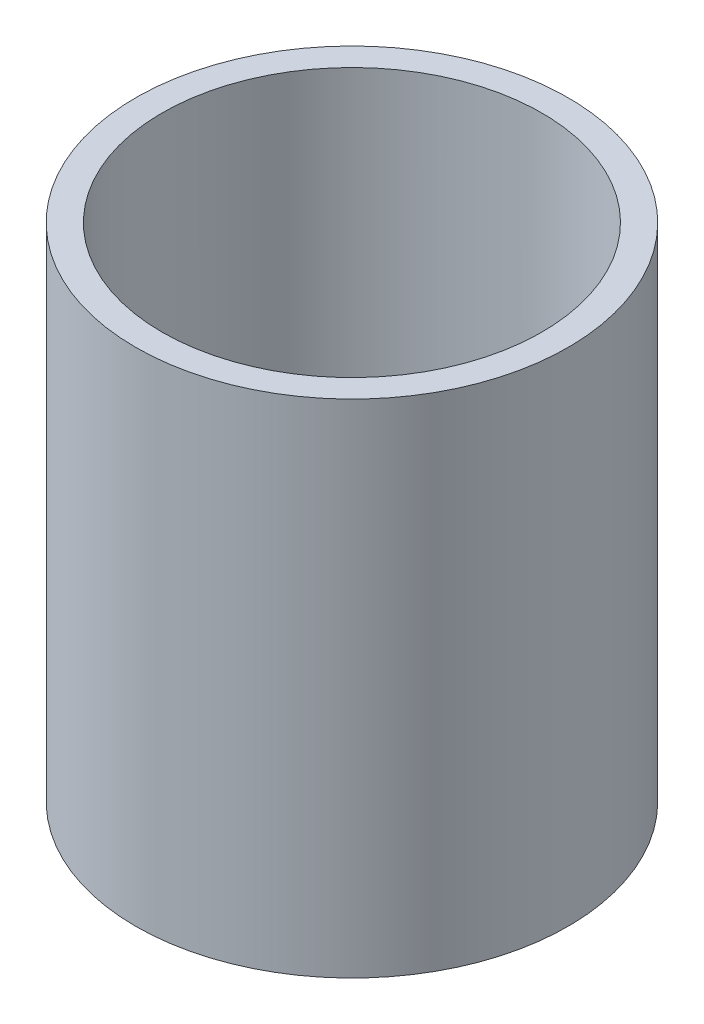
from build123d import *

# Parameters (mm, degrees)
SKETCH1_R           = 37.95
BOSS_EXTRUDE1_DEPTH = 8
SKETCH2_R           = 1.7
CUT_EXTRUDE1_DEPTH  = 9
CUT_EXTRUDE2_DEPTH  = 4
SKETCH4_R           = 37.95
SKETCH4_R_2         = 33.327499075
BOSS_EXTRUDE2_DEPTH = 80


with BuildPart() as part:
    # Sketch1 → Boss-Extrude1 (new body)
    with BuildSketch(Plane(origin=(0, 0, 0), x_dir=(1, 0, 0), z_dir=(0, 1, 0))):
        Circle(SKETCH1_R)
    extrude(amount=BOSS_EXTRUDE1_DEPTH)

    # Sketch2 → Cut-Extrude1 (cut, through all)
    with BuildSketch(Plane(origin=(0, 8, 0), x_dir=(1, 0, 0), z_dir=(0, 1, 0))):
        with Locations((0, 29.95)):
            Circle(SKETCH2_R)
        with Locations((29.95, 0)):
            Circle(SKETCH2_R)
        with Locations((0, -29.95)):
            Circle(SKETCH2_R)
        with Locations((-29.95, 0)):
            Circle(SKETCH2_R)
    extrude(amount=-CUT_EXTRUDE1_DEPTH, mode=Mode.SUBTRACT)

    # Sketch3 → Cut-Extrude2 (cut)
    with BuildSketch(Plane(origin=(0, 8, 0), x_dir=(1, 0, 0), z_dir=(0, 1, 0))):
        Polygon((26.572500925, 0), (28.261250463, -2.925), (31.638749537, -2.925), (33.327499075, 0), (31.638749537, 2.925), (28.261250463, 2.925), align=None)
        Polygon((0, 26.572500925), (2.925, 28.261250463), (2.925, 31.638749537), (0, 33.327499075), (-2.925, 31.638749537), (-2.925, 28.261250463), align=None)
        Polygon((0, -26.572500925), (-2.925, -28.261250463), (-2.925, -31.638749537), (0, -33.327499075), (2.925, -31.638749537), (2.925, -28.261250463), align=None)
        Polygon((-26.572500925, 0), (-28.261250463, 2.925), (-31.638749537, 2.925), (-33.327499075, 0), (-31.638749537, -2.925), (-28.261250463, -2.925), align=None)
    extrude(amount=-CUT_EXTRUDE2_DEPTH, mode=Mode.SUBTRACT)

    # Sketch4 → Boss-Extrude2 (add)
    with BuildSketch(Plane(origin=(0, 8, 0), x_dir=(1, 0, 0), z_dir=(0, 1, 0))):
        Circle(SKETCH4_R)
        Circle(SKETCH4_R_2, mode=Mode.SUBTRACT)
    extrude(amount=BOSS_EXTRUDE2_DEPTH)


solid = part.part
